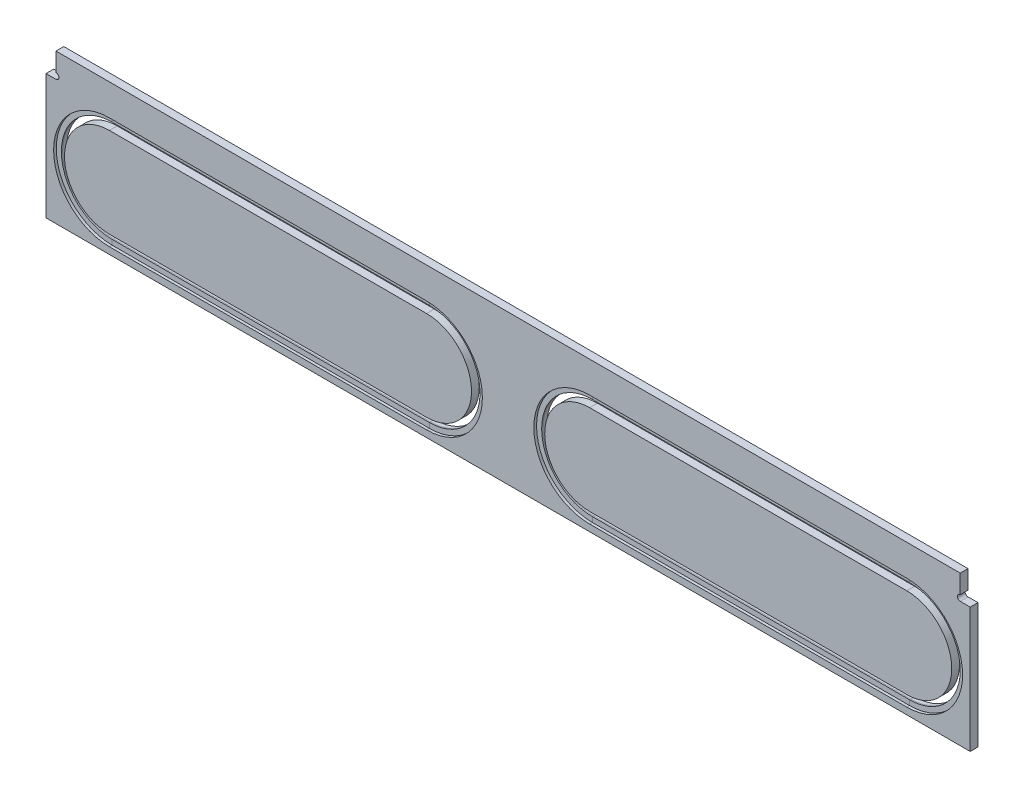
from build123d import *

# Parameters (mm, degrees)
BOSS_EXTRUDE1_DEPTH = 4.3


with BuildPart() as part:
    # Sketch1 → Boss-Extrude1 (new body, symmetric)
    with BuildSketch(Plane.XY):
        with BuildLine():
            Line((-510, 69), (-499, 69))
            ThreePointArc((-499, 69), (-495.825, 72.175), (-499, 75.35))
            Line((-499, 75.35), (-499, 96))
            Line((-499, 96), (499, 96))
            Line((499, 96), (499, 75.35))
            ThreePointArc((499, 75.35), (495.825, 72.175), (499, 69))
            Line((499, 69), (510, 69))
            Line((510, 69), (510, -69))
            Line((510, -69), (-510, -69))
            Line((-510, -69), (-510, 69))
        make_face()
    extrude(amount=BOSS_EXTRUDE1_DEPTH, both=True)

    # Cut-Sweep2: sweep along a path in Sketch2
    with BuildLine(Plane.XY) as cut_sweep2_path:
        Line((-440, 50), (-90, 50))
        ThreePointArc((-90, 50), (-40, 0), (-90, -50))
        Line((-90, -50), (-440, -50))
        ThreePointArc((-440, -50), (-490, 0), (-440, 50))
    # Sketch3 → Cut-Sweep2 (sweep, cut)
    with BuildSketch(Plane(origin=(-440, 0, 0), x_dir=(0, 0, -1), z_dir=(1, 0, 0))):
        Polygon((5.15697951, 56), (0.014113459, 56), (-1.3, 56), (-1.3, 61.6), (-5.275031484, 61.6), (-5.275031484, 49.6), (5.15697951, 49.6), align=None)
    sweep(path=cut_sweep2_path.line, mode=Mode.SUBTRACT)

    # Cut-Sweep3: sweep along a path in Sketch2_3
    with BuildLine(Plane.XY) as cut_sweep3_path:
        Line((440, 50), (90, 50))
        ThreePointArc((90, 50), (40, 0), (90, -50))
        Line((90, -50), (440, -50))
        ThreePointArc((440, -50), (490, 0), (440, 50))
    # Sketch4 → Cut-Sweep3 (sweep, cut)
    with BuildSketch(Plane(origin=(440, 0, 0), x_dir=(0, 0, -1), z_dir=(1, 0, 0))):
        Polygon((0.014113459, 56), (-1.3, 56), (-1.3, 61.6), (-5.275031484, 61.6), (-5.275031484, 49.6), (5.15697951, 49.6), (5.15697951, 56), align=None)
    sweep(path=cut_sweep3_path.line, mode=Mode.SUBTRACT)


solid = part.part
